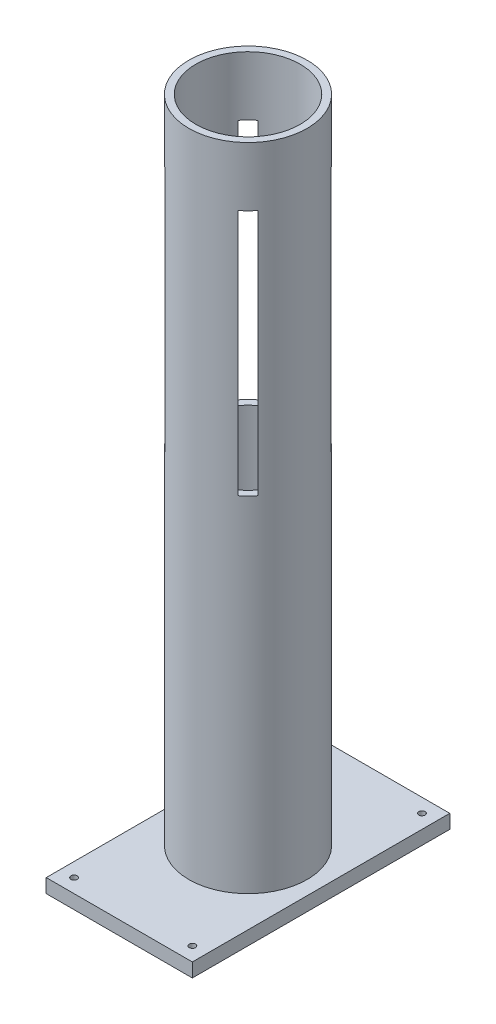
from build123d import *

# Parameters (mm, degrees)
SKETCH1_W           = 210
SKETCH1_H           = 370
BOSS_EXTRUDE1_DEPTH = 20
SKETCH2_R           = 85
BOSS_EXTRUDE2_DEPTH = 935
SKETCH3_R           = 75
CUT_EXTRUDE1_DEPTH  = 956
SKETCH4_R           = 4.5
CUT_EXTRUDE2_DEPTH  = 956
SKETCH5_R           = 9
CUT_EXTRUDE3_DEPTH  = 8.8
SKETCH7_W           = 20
SKETCH7_H           = 355
CUT_EXTRUDE4_DEPTH  = 291.060966544
SKETCH8_W           = 20
SKETCH8_H           = 355
CUT_EXTRUDE5_DEPTH  = 291.060966544


with BuildPart() as part:
    # Sketch1 → Boss-Extrude1 (new body)
    with BuildSketch(Plane(origin=(0, 0, 0), x_dir=(1, 0, 0), z_dir=(0, 1, 0))):
        Rectangle(SKETCH1_W, SKETCH1_H)
    extrude(amount=BOSS_EXTRUDE1_DEPTH)

    # Sketch2 → Boss-Extrude2 (add)
    with BuildSketch(Plane(origin=(0, 20, 0), x_dir=(1, 0, 0), z_dir=(0, 1, 0))):
        Circle(SKETCH2_R)
    extrude(amount=BOSS_EXTRUDE2_DEPTH)

    # Sketch3 → Cut-Extrude1 (cut, through all)
    with BuildSketch(Plane(origin=(0, 955, 0), x_dir=(1, 0, 0), z_dir=(0, 1, 0))):
        Circle(SKETCH3_R)
    extrude(amount=-CUT_EXTRUDE1_DEPTH, mode=Mode.SUBTRACT)

    # Sketch4 → Cut-Extrude2 (cut, through all)
    with BuildSketch(Plane.XZ):
        with Locations((-85, 165)):
            Circle(SKETCH4_R)
        with Locations((85, 165)):
            Circle(SKETCH4_R)
        with Locations((85, -165)):
            Circle(SKETCH4_R)
        with Locations((-85, -165)):
            Circle(SKETCH4_R)
    extrude(amount=-CUT_EXTRUDE2_DEPTH, mode=Mode.SUBTRACT)

    # Sketch5 → Cut-Extrude3 (cut)
    with BuildSketch(Plane.XZ):
        with Locations((-85, 165)):
            Circle(SKETCH5_R)
        with Locations((85, 165)):
            Circle(SKETCH5_R)
        with Locations((85, -165)):
            Circle(SKETCH5_R)
        with Locations((-85, -165)):
            Circle(SKETCH5_R)
    extrude(amount=-CUT_EXTRUDE3_DEPTH, mode=Mode.SUBTRACT)

    # Sketch7 → Cut-Extrude4 (cut, through all)
    with BuildSketch(Plane(origin=(60.104076401, 0, 60.104076401), x_dir=(0.707106781, 0, -0.707106781), z_dir=(0.707106781, 0, 0.707106781))):
        with Locations((0, 692.5)):
            Rectangle(SKETCH7_W, SKETCH7_H)
    extrude(amount=-CUT_EXTRUDE4_DEPTH, mode=Mode.SUBTRACT)

    # Sketch8 → Cut-Extrude5 (cut, through all)
    with BuildSketch(Plane(origin=(60.104076401, 0, -60.104076401), x_dir=(-0.707106781, 0, -0.707106781), z_dir=(0.707106781, 0, -0.707106781))):
        with Locations((0, 692.5)):
            Rectangle(SKETCH8_W, SKETCH8_H)
    extrude(amount=-CUT_EXTRUDE5_DEPTH, mode=Mode.SUBTRACT)


solid = part.part
